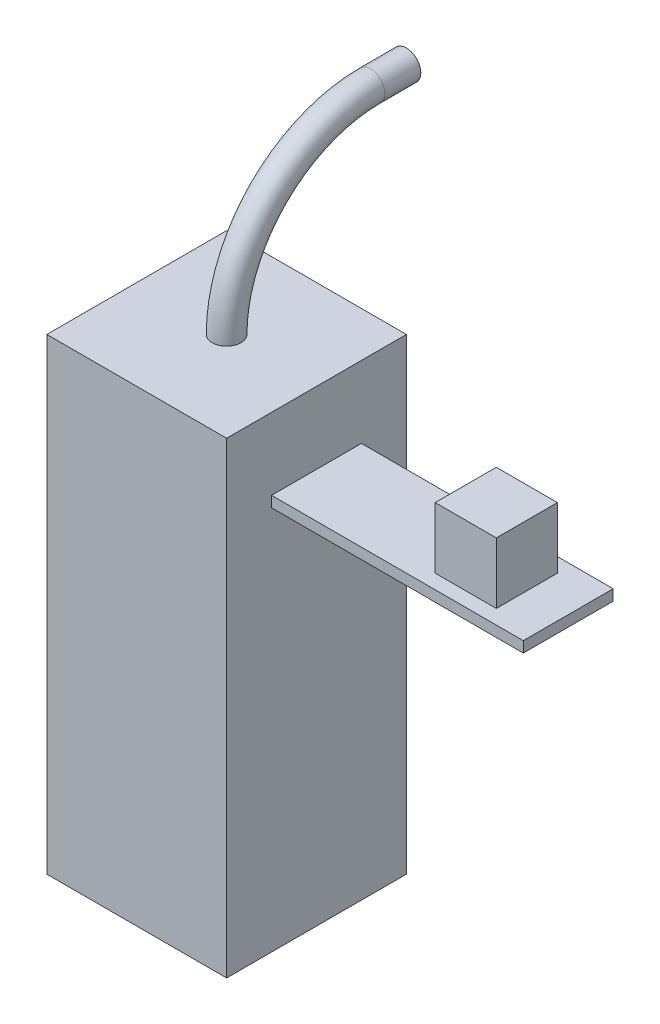
from build123d import *

# Parameters (mm, degrees)
ESBO_O1_W                = 50
ESBO_O1_H                = 50
RESSALTO_EXTRUS_O1_DEPTH = 130
ESBO_O2_W                = 25
ESBO_O2_H                = 3
RESSALTO_EXTRUS_O2_DEPTH = 70
ESBO_O4_W                = 17
ESBO_O4_H                = 17
RESSALTO_EXTRUS_O3_DEPTH = 17
ESBO_O5_R                = 4


with BuildPart() as part:
    # Esboço1 → Ressalto-extrusão1 (new body)
    with BuildSketch(Plane(origin=(0, 0, 0), x_dir=(1, 0, 0), z_dir=(0, 1, 0))):
        Rectangle(ESBO_O1_W, ESBO_O1_H)
    extrude(amount=RESSALTO_EXTRUS_O1_DEPTH)

    # Esboço2 → Ressalto-extrusão2 (add)
    with BuildSketch(Plane(origin=(25, 0, 0), x_dir=(0, 0, -1), z_dir=(1, 0, 0))):
        with Locations((0, 108.5)):
            Rectangle(ESBO_O2_W, ESBO_O2_H)
    extrude(amount=RESSALTO_EXTRUS_O2_DEPTH)

    # Esboço4 → Ressalto-extrusão3 (add)
    with BuildSketch(Plane(origin=(0, 110, 0), x_dir=(1, 0, 0), z_dir=(0, 1, 0))):
        with Locations((75, 0)):
            Rectangle(ESBO_O4_W, ESBO_O4_H)
    extrude(amount=RESSALTO_EXTRUS_O3_DEPTH)

    # Varredura1: sweep along a path in Esboço6
    with BuildLine(Plane(origin=(0, 0, 0), x_dir=(0, 0, -1), z_dir=(1, 0, 0))) as varredura1_path:
        Line((50, 170), (40, 170))
        ThreePointArc((40, 170), (11.715728753, 158.284271247), (0, 130))
    # Esboço5 → Varredura1 (sweep)
    with BuildSketch(Plane(origin=(0, 130, 0), x_dir=(1, 0, 0), z_dir=(0, 1, 0))):
        Circle(ESBO_O5_R)
    sweep(path=varredura1_path.line)


solid = part.part
